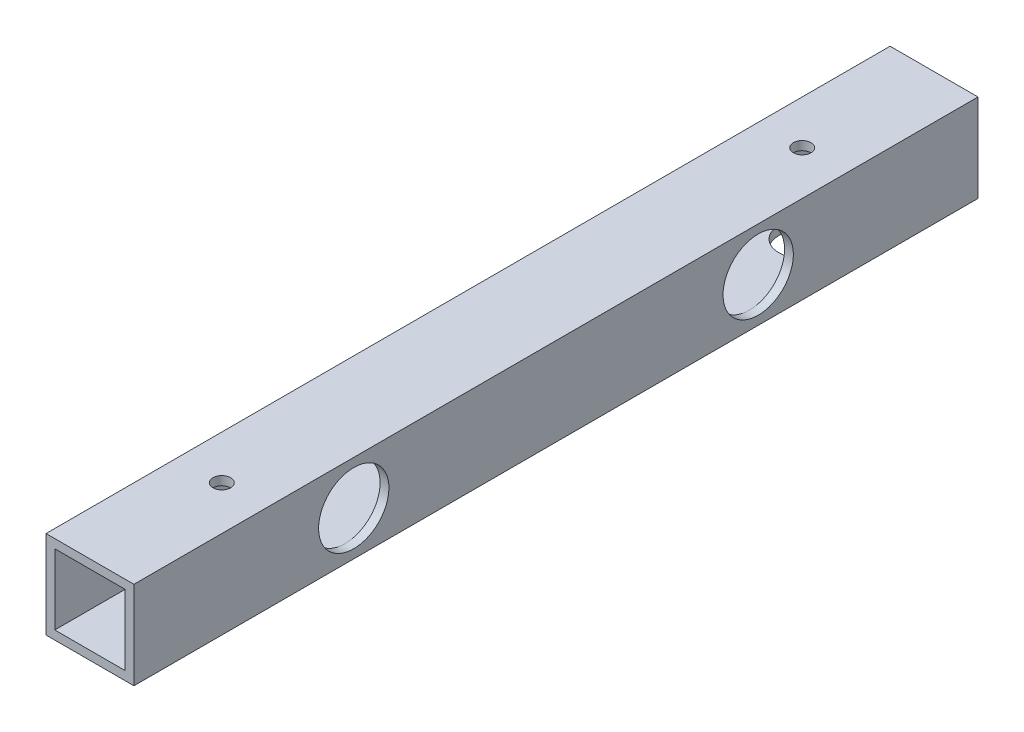
from build123d import *

# Parameters (mm, degrees)
SKETCH_1_W           = 15
SKETCH_1_H           = 15
SKETCH_1_W_2         = 12
SKETCH_1_H_2         = 12
EXTRUDE_2_DEPTH      = 144
SKETCH_2_R           = 1.5
CUT_EXTRUDE_1_DEPTH  = 10
SKETCH_3_R           = 1.5
CUT_EXTRUDE_2_DEPTH  = 10
SKETCH_4_R           = 1.5
CUT_EXTRUDE_4_DEPTH  = 10
SKETCH_6_R           = 1.5
CUT_EXTRUDE_5_DEPTH  = 10
SKETCH_7_R           = 4
CUT_EXTRUDE_6_DEPTH  = 10
SKETCH_8_R           = 4
CUT_EXTRUDE_7_DEPTH  = 10
SKETCH_9_R           = 1.5
CUT_EXTRUDE_8_DEPTH  = 10
SKETCH_10_R          = 6
CUT_EXTRUDE_9_DEPTH  = 10
SKETCH_11_R          = 4
CUT_EXTRUDE_10_DEPTH = 10
SKETCH_12_R          = 1.5
CUT_EXTRUDE_11_DEPTH = 10
SKETCH_13_R          = 6
CUT_EXTRUDE_12_DEPTH = 10


with BuildPart() as part:
    # ｽｹｯﾁ1 → ﾎﾞｽ - 押し出し2 (new body)
    with BuildSketch(Plane.XY):
        with Locations((0.489915859, 0.232626086)):
            Rectangle(SKETCH_1_W, SKETCH_1_H)
        with Locations((0.489915859, 0.232626086)):
            Rectangle(SKETCH_1_W_2, SKETCH_1_H_2, mode=Mode.SUBTRACT)
    extrude(amount=EXTRUDE_2_DEPTH)

    # ｽｹｯﾁ2 → ｶｯﾄ - 押し出し1 (cut)
    with BuildSketch(Plane.ZY.offset(7.010084141)):
        with Locations((72.5, 0.232626086)):
            Circle(SKETCH_2_R)
    extrude(amount=-CUT_EXTRUDE_1_DEPTH, mode=Mode.SUBTRACT)

    # ｽｹｯﾁ3 → ｶｯﾄ - 押し出し2 (cut)
    with BuildSketch(Plane(origin=(0, 7.732626086, 0), x_dir=(1, 0, 0), z_dir=(0, 1, 0))):
        with Locations((0.489915859, -22.5)):
            Circle(SKETCH_3_R)
    extrude(amount=-CUT_EXTRUDE_2_DEPTH, mode=Mode.SUBTRACT)

    # ｽｹｯﾁ4 → ｶｯﾄ - 押し出し4 (cut)
    with BuildSketch(Plane(origin=(0, 7.732626086, 0), x_dir=(1, 0, 0), z_dir=(0, 1, 0))):
        with Locations((0.489915859, -121.5)):
            Circle(SKETCH_4_R)
    extrude(amount=-CUT_EXTRUDE_4_DEPTH, mode=Mode.SUBTRACT)

    # ｽｹｯﾁ6 → ｶｯﾄ - 押し出し5 (cut)
    with BuildSketch(Plane.ZY.offset(7.010084141)):
        with Locations((7.5, 0.232626086)):
            Circle(SKETCH_6_R)
    extrude(amount=-CUT_EXTRUDE_5_DEPTH, mode=Mode.SUBTRACT)

    # ｽｹｯﾁ7 → ｶｯﾄ - 押し出し6 (cut)
    with BuildSketch(Plane.XZ.offset(7.267373914)):
        with Locations((0.489915859, 22.5)):
            Circle(SKETCH_7_R)
    extrude(amount=-CUT_EXTRUDE_6_DEPTH, mode=Mode.SUBTRACT)

    # ｽｹｯﾁ8 → ｶｯﾄ - 押し出し7 (cut)
    with BuildSketch(Plane.XZ.offset(7.267373914)):
        with Locations((0.489915859, 121.5)):
            Circle(SKETCH_8_R)
    extrude(amount=-CUT_EXTRUDE_7_DEPTH, mode=Mode.SUBTRACT)

    # ｽｹｯﾁ9 → ｶｯﾄ - 押し出し8 (cut)
    with BuildSketch(Plane.ZY.offset(7.010084141)):
        with Locations((37.5, 0.232626086)):
            Circle(SKETCH_9_R)
    extrude(amount=-CUT_EXTRUDE_8_DEPTH, mode=Mode.SUBTRACT)

    # ｽｹｯﾁ10 → ｶｯﾄ - 押し出し9 (cut)
    with BuildSketch(Plane(origin=(7.989915859, 0, 0), x_dir=(0, 0, -1), z_dir=(1, 0, 0))):
        with Locations((-37.5, 0.232626086)):
            Circle(SKETCH_10_R)
    extrude(amount=-CUT_EXTRUDE_9_DEPTH, mode=Mode.SUBTRACT)

    # ｽｹｯﾁ11 → ｶｯﾄ - 押し出し10 (cut)
    with BuildSketch(Plane.XZ.offset(7.267373914)):
        with Locations((0.489915859, 72.5)):
            Circle(SKETCH_11_R)
    extrude(amount=-CUT_EXTRUDE_10_DEPTH, mode=Mode.SUBTRACT)

    # ｽｹｯﾁ12 → ｶｯﾄ - 押し出し11 (cut)
    with BuildSketch(Plane.ZY.offset(7.010084141)):
        with Locations((106.5, 0.232626086)):
            Circle(SKETCH_12_R)
    extrude(amount=-CUT_EXTRUDE_11_DEPTH, mode=Mode.SUBTRACT)

    # ｽｹｯﾁ13 → ｶｯﾄ - 押し出し12 (cut)
    with BuildSketch(Plane(origin=(7.989915859, 0, 0), x_dir=(0, 0, -1), z_dir=(1, 0, 0))):
        with Locations((-106.5, 0.232626086)):
            Circle(SKETCH_13_R)
    extrude(amount=-CUT_EXTRUDE_12_DEPTH, mode=Mode.SUBTRACT)


solid = part.part
